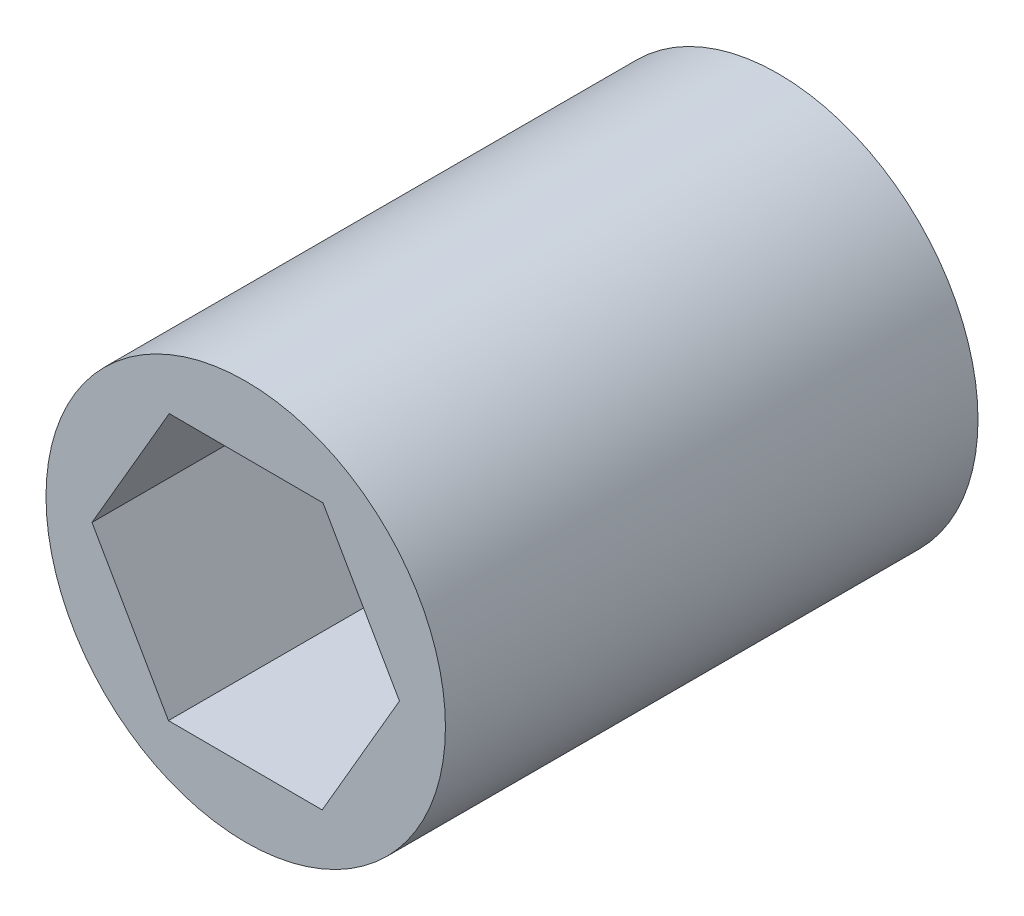
from build123d import *

# Parameters (mm, degrees)
SKETCH1_R           = 9.525
BOSS_EXTRUDE1_DEPTH = 25.4


with BuildPart() as part:
    # Sketch1 → Boss-Extrude1 (new body)
    with BuildSketch(Plane.XY):
        Circle(SKETCH1_R)
        Polygon((3.64699361, -6.361035367), (7.332315027, -0.022128569), (3.685321417, 6.338906797), (-3.64699361, 6.361035367), (-7.332315027, 0.022128569), (-3.685321417, -6.338906797), align=None, mode=Mode.SUBTRACT)
    extrude(amount=BOSS_EXTRUDE1_DEPTH)


solid = part.part
